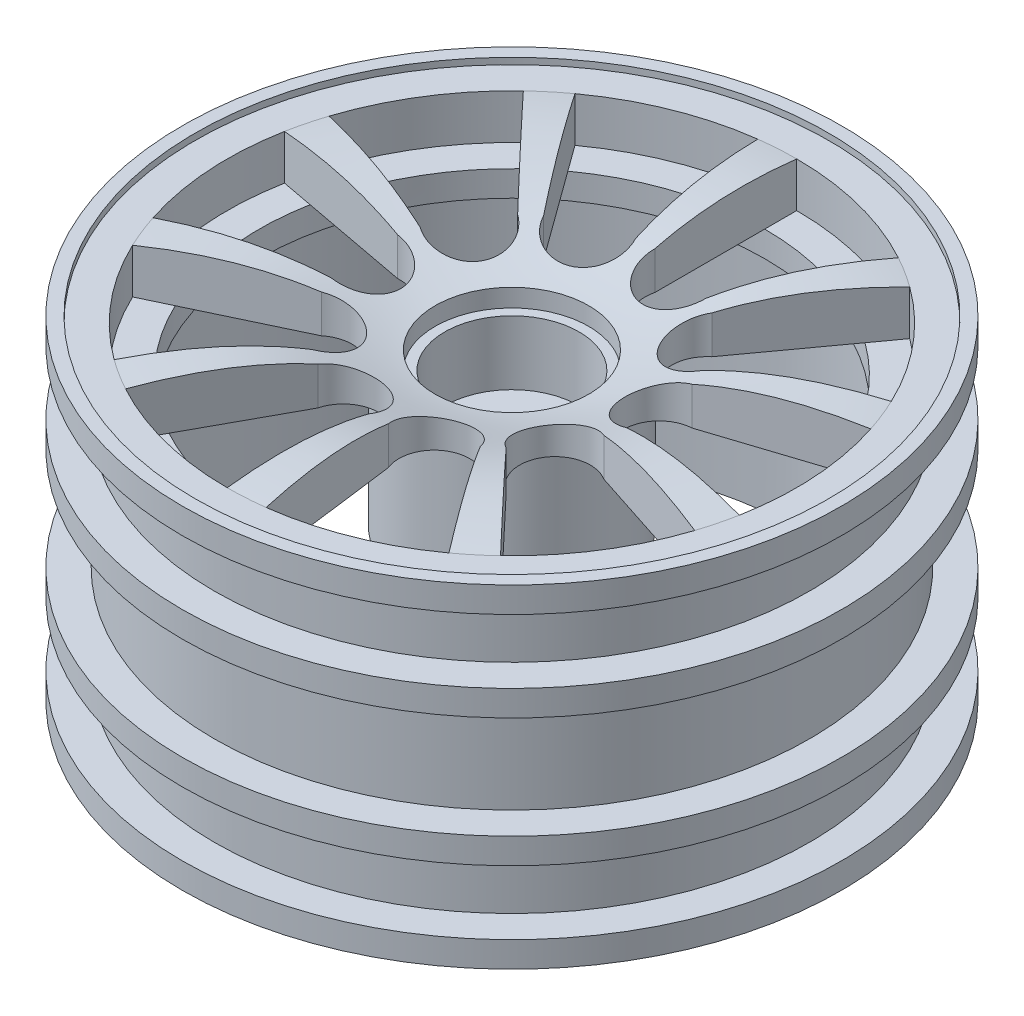
from build123d import *

# Parameters (mm, degrees)
SKETCH4_R           = 4.5
BOSS_EXTRUDE1_DEPTH = 5.5
CUT_EXTRUDE1_DEPTH  = 5
SKETCH6_R           = 5.25
CUT_EXTRUDE2_DEPTH  = 5
SKETCH7_R           = 2
CUT_EXTRUDE3_DEPTH  = 10.202837764
CUT_EXTRUDE4_DEPTH  = 27
CIRPATTERN1_COUNT   = 10
SKETCH10_R          = 22.25
SKETCH10_R_2        = 19.75
BOSS_EXTRUDE4_DEPTH = 2


with BuildPart() as part:
    # Sketch2 → Revolve1 (revolve)
    with BuildSketch(Plane.XY):
        with BuildLine():
            Line((25.75, 0), (24.75, 0))
            Line((24.75, 0), (24.75, -0.5))
            Line((24.75, -0.5), (22.25, -0.5))
            add(Edge.make_bspline(
                [(22.25, -0.5), (18.956988134, -0.112229077), (13.339059948, -0.0971285), (8.128157106, -1.94629967), (6, -2.302837764)],
                knots=[0, 0, 0, 0, 0.607536281, 1, 1, 1, 1], degree=3))
            Line((6, -2.302837764), (6, -3.702837764))
            Line((6, -3.702837764), (4.5, -3.702837764))
            Line((4.5, -3.702837764), (4.5, -9.202837764))
            Line((4.5, -9.202837764), (6, -9.202837764))
            Line((6, -9.202837764), (6, -14.302837764))
            Line((6, -14.302837764), (7.93, -14.302837764))
            Line((7.93, -14.302837764), (7.93, -4))
            Line((7.93, -4), (18.919553651, -4))
            Line((18.919553651, -4), (22.25, -4))
            Line((22.25, -4), (22.25, -5.5))
            Line((22.25, -5.5), (22.25, -25.5))
            Line((22.25, -25.5), (24.75, -25.5))
            Line((24.75, -25.5), (24.75, -26))
            Line((24.75, -26), (25.75, -26))
            Line((25.75, -26), (25.75, -24))
            Line((25.75, -24), (23.25, -24))
            Line((23.25, -24), (23.25, -19))
            Line((23.25, -19), (25.75, -19))
            Line((25.75, -19), (25.75, -17))
            Line((25.75, -17), (23.25, -17))
            Line((23.25, -17), (23.25, -9))
            Line((23.25, -9), (25.75, -9))
            Line((25.75, -9), (25.75, -7))
            Line((25.75, -7), (23.25, -7))
            Line((23.25, -7), (23.25, -5.5))
            Line((23.25, -5.5), (23.25, -2))
            Line((23.25, -2), (25.75, -2))
            Line((25.75, -2), (25.75, 0))
        make_face()
    revolve(axis=Axis((0, 14.330159705, 0), (0, -1, 0)))

    # Sketch4 → Boss-Extrude1 (add)
    with BuildSketch(Plane(origin=(0, -3.702837764, 0), x_dir=(1, 0, 0), z_dir=(0, 1, 0))):
        Circle(SKETCH4_R)
    extrude(amount=-BOSS_EXTRUDE1_DEPTH)

    # Sketch5 → Cut-Extrude1 (cut)
    with BuildSketch(Plane.XZ.offset(14.302837764)):
        Polygon((1.07374697, -6.844491759), (6.464377225, -2.492353726), (5.390630255, 4.352138033), (-1.07374697, 6.844491759), (-6.464377225, 2.492353726), (-5.390630255, -4.352138033), align=None)
    extrude(amount=-CUT_EXTRUDE1_DEPTH, mode=Mode.SUBTRACT)

    # Sketch6 → Cut-Extrude2 (cut)
    with BuildSketch(Plane(origin=(0, -3.702837764, 0), x_dir=(1, 0, 0), z_dir=(0, 1, 0))):
        Circle(SKETCH6_R)
    extrude(amount=-CUT_EXTRUDE2_DEPTH, mode=Mode.SUBTRACT)

    # Sketch7 → Cut-Extrude3 (cut, through all)
    with BuildSketch(Plane(origin=(0, -9.202837764, 0), x_dir=(-1, 0, 0), z_dir=(0, -1, 0))):
        Circle(SKETCH7_R)
    extrude(amount=-CUT_EXTRUDE3_DEPTH, mode=Mode.SUBTRACT)

    # Sketch8 → Cut-Extrude4 (cut, through all)
    with BuildSketch(Plane(origin=(0, 0, 0), x_dir=(1, 0, 0), z_dir=(0, 1, 0))):
        with BuildLine():
            Line((0, 22.25), (0, 11.178786977))
            ThreePointArc((0, 11.178786977), (1.994479823, 7.818183458), (5.355083342, 9.812663281))
            Line((5.355083342, 9.812663281), (10.658634485, 19.530898876))
            ThreePointArc((10.658634485, 19.530898876), (5.5, 21.559510662), (0, 22.25))
        make_face()
    cut_extrude4 = extrude(amount=-CUT_EXTRUDE4_DEPTH, mode=Mode.SUBTRACT)

    # CirPattern1: Cut-Extrude4 ×10 about axis
    cirpattern1_axis = Axis((0, 0, 0), (0, 1, 0))
    for i in range(1, CIRPATTERN1_COUNT):
        add(cut_extrude4.rotate(cirpattern1_axis, i * 360 / CIRPATTERN1_COUNT), mode=Mode.SUBTRACT)

    # Sketch10 → Boss-Extrude4 (add)
    with BuildSketch(Plane.XZ.offset(4)):
        Circle(SKETCH10_R)
        Circle(SKETCH10_R_2, mode=Mode.SUBTRACT)
    extrude(amount=BOSS_EXTRUDE4_DEPTH)


solid = part.part
